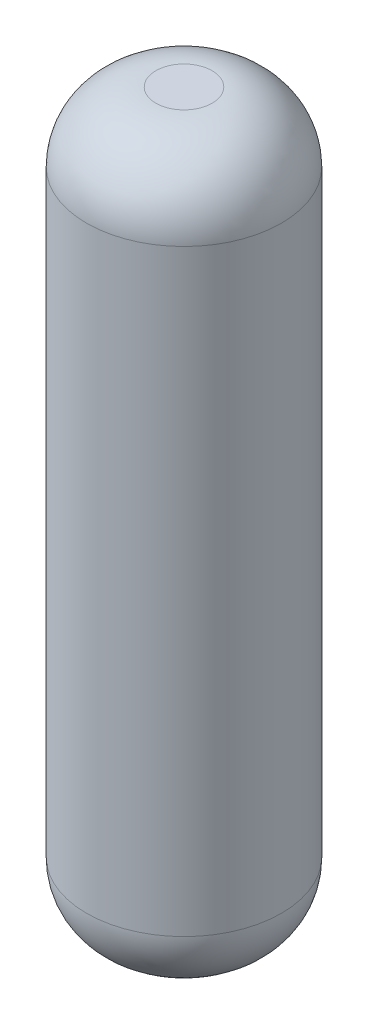
from build123d import *

# Parameters (mm, degrees)
SKETCH1_R           = 57.15
BOSS_EXTRUDE1_DEPTH = 431.8
FILLET1_R           = 40.64


with BuildPart() as part:
    # Sketch1 → Boss-Extrude1 (new body)
    with BuildSketch(Plane(origin=(0, 0, 0), x_dir=(1, 0, 0), z_dir=(0, 1, 0))):
        Circle(SKETCH1_R)
    extrude(amount=BOSS_EXTRUDE1_DEPTH)

    # Fillet1
    fillet1_edges = [part.edges().sort_by_distance(p)[0] for p in [
        (-57.15, 0, 0),
        (-57.15, 431.8, 0),
    ]]
    fillet(fillet1_edges, radius=FILLET1_R)


solid = part.part
